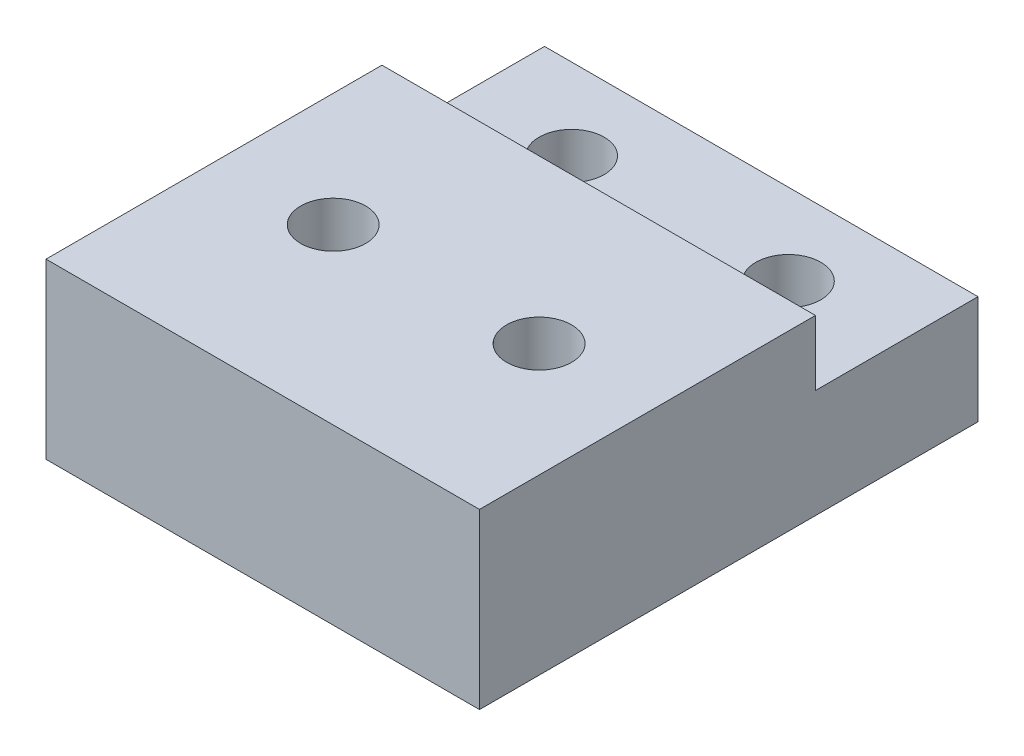
from build123d import *

# Parameters (mm, degrees)
CROQUIS1_W              = 20
CROQUIS1_H              = 17.5
SALIENTE_EXTRUIR1_DEPTH = 8
CROQUIS1_4_W            = 20
CROQUIS1_4_H            = 7.5
SALIENTE_EXTRUIR2_DEPTH = 5
CROQUIS2_R              = 1.5
CORTAR_EXTRUIR1_DEPTH   = 5
CROQUIS3_R              = 1.5
CORTAR_EXTRUIR2_DEPTH   = 20
CROQUIS4_W              = 20
CROQUIS4_H              = 2
CORTAR_EXTRUIR3_DEPTH   = 35


with BuildPart() as part:
    # Croquis1 → Saliente-Extruir1 (new body)
    with BuildSketch(Plane(origin=(0, 0, 0), x_dir=(1, 0, 0), z_dir=(0, 1, 0))):
        with Locations((0, -3.75)):
            Rectangle(CROQUIS1_W, CROQUIS1_H)
    extrude(amount=SALIENTE_EXTRUIR1_DEPTH)

    # Croquis1_4 → Saliente-Extruir2 (add)
    with BuildSketch(Plane(origin=(0, 0, 0), x_dir=(1, 0, 0), z_dir=(0, 1, 0))):
        with Locations((0, 8.75)):
            Rectangle(CROQUIS1_4_W, CROQUIS1_4_H)
    extrude(amount=SALIENTE_EXTRUIR2_DEPTH)

    # Croquis2 → Cortar-Extruir1 (cut)
    with BuildSketch(Plane(origin=(0, 5, 0), x_dir=(1, 0, 0), z_dir=(0, 1, 0))):
        with Locations((-5, 8.75)):
            Circle(CROQUIS2_R)
        with Locations((5, 8.75)):
            Circle(CROQUIS2_R)
    extrude(amount=-CORTAR_EXTRUIR1_DEPTH, mode=Mode.SUBTRACT)

    # Croquis3 → Cortar-Extruir2 (cut)
    with BuildSketch(Plane(origin=(0, 8, 0), x_dir=(1, 0, 0), z_dir=(0, 1, 0))):
        with Locations((-4.75, -2.5)):
            Circle(CROQUIS3_R)
        with Locations((4.75, -2.5)):
            Circle(CROQUIS3_R)
    extrude(amount=-CORTAR_EXTRUIR2_DEPTH, mode=Mode.SUBTRACT)

    # Croquis4 → Cortar-Extruir3 (cut)
    with BuildSketch(Plane(origin=(0, 8, 0), x_dir=(1, 0, 0), z_dir=(0, 1, 0))):
        with Locations((0, -11.5)):
            Rectangle(CROQUIS4_W, CROQUIS4_H)
    extrude(amount=-CORTAR_EXTRUIR3_DEPTH, mode=Mode.SUBTRACT)


solid = part.part
